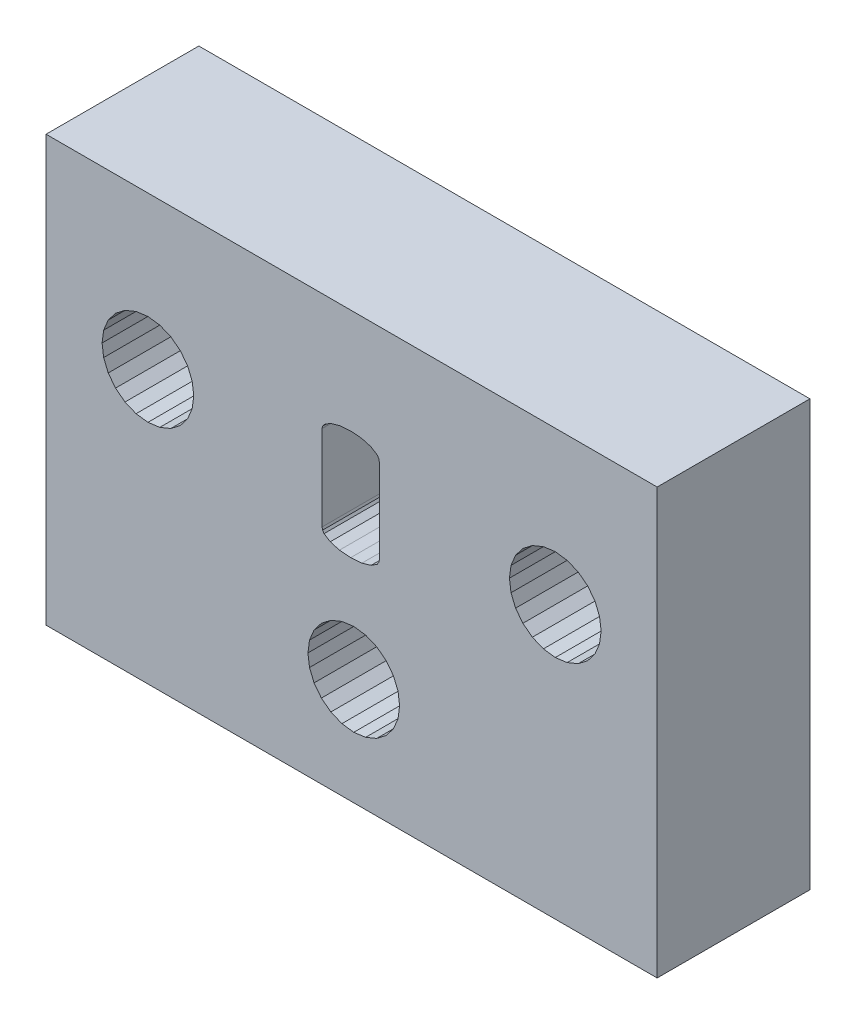
from build123d import *

# Parameters (mm, degrees)
SKETCH1_W           = 23.99999232
SKETCH1_H           = 16.699994656
BOSS_EXTRUDE1_DEPTH = 6


with BuildPart() as part:
    # Sketch1 → Boss-Extrude1 (new body)
    with BuildSketch(Plane.XY):
        with Locations((252.938699812, 68.084795762)):
            Rectangle(SKETCH1_W, SKETCH1_H)
        Polygon((260.471706709, 68.696129079), (260.937580841, 68.634795586), (261.403454973, 68.696129079), (261.837580553, 68.875949782), (262.21037264, 69.162003211), (262.496426069, 69.534795298), (262.676246772, 69.968920878), (262.737580265, 70.43479501), (262.676246772, 70.900669142), (262.496426069, 71.334794722), (262.21037264, 71.707586809), (261.837580553, 71.993640238), (261.403454973, 72.173460941), (260.937580841, 72.234794434), (260.471706709, 72.173460941), (260.037581129, 71.993640238), (259.664789043, 71.707586809), (259.378735613, 71.334794722), (259.19891491, 70.900669142), (259.137581417, 70.43479501), (259.19891491, 69.968920878), (259.378735613, 69.534795298), (259.664789043, 69.162003211), (260.037581129, 68.875949782), align=None, mode=Mode.SUBTRACT)
        Polygon((243.665910573, 69.162003211), (244.03870266, 68.875949782), (244.47282824, 68.696129079), (244.938702372, 68.634795586), (245.404576504, 68.696129079), (245.838702084, 68.875949782), (246.211494171, 69.162003211), (246.4975476, 69.534795298), (246.677368303, 69.968920878), (246.738701796, 70.43479501), (246.677368303, 70.900669142), (246.4975476, 71.334794722), (246.211494171, 71.707586809), (245.838702084, 71.993640238), (245.404576504, 72.173460941), (244.938702372, 72.234794434), (244.47282824, 72.173460941), (244.03870266, 71.993640238), (243.665910573, 71.707586809), (243.379857144, 71.334794722), (243.200036441, 70.900669142), (243.138702948, 70.43479501), (243.200036441, 69.968920878), (243.379857144, 69.534795298), align=None, mode=Mode.SUBTRACT)
        Polygon((251.464618748, 63.034797378), (251.750672178, 62.662005291), (252.123464264, 62.375951862), (252.557589844, 62.196131159), (253.023463976, 62.134797666), (253.489338109, 62.196131159), (253.923463688, 62.375951862), (254.296255775, 62.662005291), (254.582309204, 63.034797378), (254.762129907, 63.468922958), (254.8234634, 63.93479709), (254.762129907, 64.400671222), (254.582309204, 64.834796802), (254.296255775, 65.207588889), (253.923463688, 65.493642318), (253.489338109, 65.673463021), (253.023463976, 65.734796514), (252.557589844, 65.673463021), (252.123464264, 65.493642318), (251.750672178, 65.207588889), (251.464618748, 64.834796802), (251.284798045, 64.400671222), (251.223464552, 63.93479709), (251.284798045, 63.468922958), align=None, mode=Mode.SUBTRACT)
        Polygon((251.777890248, 68.493953964), (251.79798719, 68.397765535), (251.858278015, 68.308990644), (252.099441315, 68.153681479), (252.460805168, 68.048319912), (252.901794593, 68.01319939), (253.342784017, 68.048319912), (253.70414787, 68.153681479), (253.94531117, 68.308990644), (254.005601995, 68.397765535), (254.025698937, 68.493953964), (254.025698937, 71.840371646), (254.005601995, 71.936560075), (253.94531117, 72.025334966), (253.70414787, 72.180644131), (253.342784017, 72.286005698), (252.901794593, 72.32112622), (252.460805168, 72.286005698), (252.099441315, 72.180644131), (251.858278015, 72.025334966), (251.79798719, 71.936560075), (251.777890248, 71.840371646), align=None, mode=Mode.SUBTRACT)
    extrude(amount=BOSS_EXTRUDE1_DEPTH)


solid = part.part
